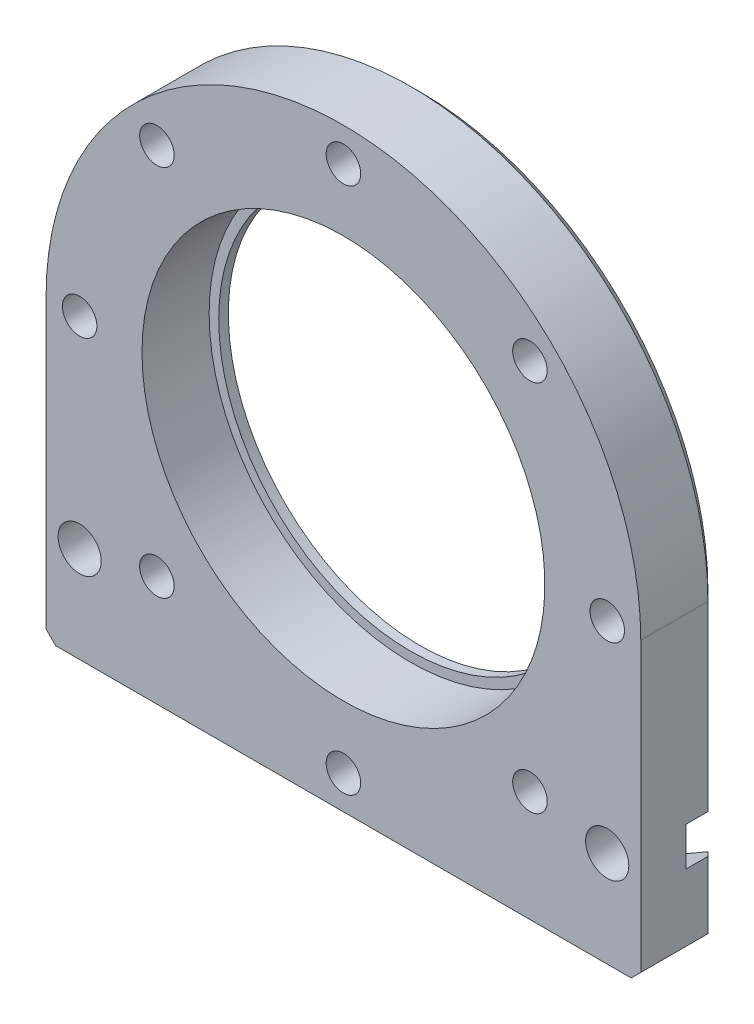
from build123d import *

# Parameters (mm, degrees)
EXTRUDE_1_DEPTH          = 8
SKETCH_2_R               = 20
CUT_EXTRUDE_1_DEPTH      = 9
HOLE_WIZARD_M3_1_D       = 3.6
PATTERN_CIRCULAR_1_COUNT = 8
CHAMFER_1_SIZE           = 1
HOLE_WIZARD_M4_1_D       = 4.5
CUT_EXTRUDE_2_DEPTH      = 3.3
SKETCH_8_R               = 21
CUT_EXTRUDE_3_DEPTH      = 7


with BuildPart() as part:
    # ｽｹｯﾁ1 → ﾎﾞｽ - 押し出し1 (new body)
    with BuildSketch(Plane.XY):
        with BuildLine():
            Line((31, -31), (-31, -31))
            Line((-31, -31), (-31, 0))
            ThreePointArc((-31, 0), (0, 31), (31, 0))
            Line((31, 0), (31, -31))
        make_face()
    extrude(amount=EXTRUDE_1_DEPTH)

    # ｽｹｯﾁ2 → ｶｯﾄ - 押し出し1 (cut, through all)
    with BuildSketch(Plane.XY.offset(8)):
        Circle(SKETCH_2_R)
    extrude(amount=-CUT_EXTRUDE_1_DEPTH, mode=Mode.SUBTRACT)

    # M3 すきま穴1 (through all)
    with Locations(Plane.XY.offset(8)):
        with Locations((0, 27.5)):
            hole_wizard_m3_1 = Hole(HOLE_WIZARD_M3_1_D / 2)

    # 円形ﾊﾟﾀｰﾝ1: M3 すきま穴1 ×8 about axis
    pattern_circular_1_axis = Axis((0, 0, 0), (0, 0, 1))
    for i in range(1, PATTERN_CIRCULAR_1_COUNT):
        add(hole_wizard_m3_1.rotate(pattern_circular_1_axis, i * 360 / PATTERN_CIRCULAR_1_COUNT), mode=Mode.SUBTRACT)

    # 面取り1
    chamfer_1_edges = [part.edges().sort_by_distance(p)[0] for p in [
        (31, -15.5, 0),
        (0, -31, 0),
        (-31, -15.5, 0),
        (0, 31, 0),
        (31, -31, 4),
        (-31, -31, 4),
    ]]
    chamfer(chamfer_1_edges, length=CHAMFER_1_SIZE)

    # M4 すきま穴1 (through all)
    with Locations(Plane.XY.offset(8)):
        with Locations((-27.5, -21), (27.5, -21)):
            Hole(HOLE_WIZARD_M4_1_D / 2)

    # ｽｹｯﾁ7 → ｶｯﾄ - 押し出し2 (cut)
    with BuildSketch(Plane.XY):
        Polygon((-27.5, -25.041451884), (-24, -23.020725942), (-24, -18.979274058), (-27.5, -16.958548116), (-31, -18.979274058), (-31, -23.020725942), align=None)
        Polygon((31, -18.979274058), (27.5, -16.958548116), (24, -18.979274058), (24, -23.020725942), (27.5, -25.041451884), (31, -23.020725942), align=None)
    extrude(amount=CUT_EXTRUDE_2_DEPTH, mode=Mode.SUBTRACT)

    # ｽｹｯﾁ8 → ｶｯﾄ - 押し出し3 (cut)
    with BuildSketch(Plane(origin=(0, 0, 8), x_dir=(-1, 0, 0), z_dir=(0, 0, -1))):
        Circle(SKETCH_8_R)
    extrude(amount=CUT_EXTRUDE_3_DEPTH, mode=Mode.SUBTRACT)


solid = part.part
